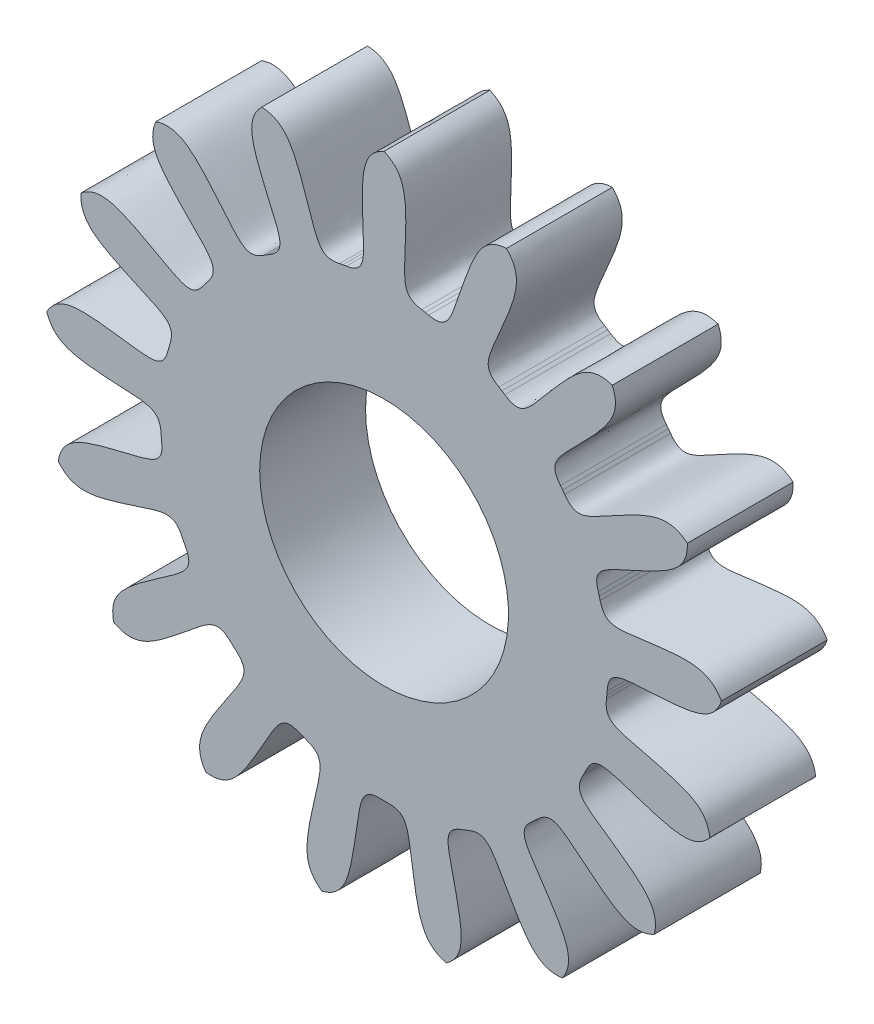
from build123d import *

# Parameters (mm, degrees)
BOSS_EXTRUDE1_17_TEETH_DEPTH = 0.6
CUT_EXTRUDE1_REACH           = 2.6
SKETCH2_R                    = 0.705


with BuildPart() as part:
    # Sketch1 → Boss-Extrude1 (17 teeth) (new body)
    with BuildSketch(Plane.XY):
        with BuildLine():
            Line((0.213306555, 1.249929723), (0.232994389, 1.24640989))
            Line((0.232994389, 1.24640989), (0.252624257, 1.242579971))
            add(Edge.make_bspline(
                [(0.693583999, 1.79034668), (0.578557942, 1.784358492), (0.516328, 1.691711636), (0.377605509, 1.288453607), (0.358256996, 1.220124862), (0.252624257, 1.242579971)],
                knots=[0, 0, 0, 0, 0.427279663, 0.527279663, 1, 1, 1, 1], degree=3))
            add(Edge.make_bspline(
                [(0.693583999, 1.79034668), (0.774555064, 1.708428802), (0.758127763, 1.598037909), (0.588971743, 1.206569891), (0.55723769, 1.14303933), (0.650429135, 1.08846954)],
                knots=[0, 0, 0, 0, 0.427279663, 0.527279663, 1, 1, 1, 1], degree=3))
            Line((0.650429135, 1.08846954), (0.667515983, 1.078075328))
            Line((0.667515983, 1.078075328), (0.684436763, 1.067412909))
            add(Edge.make_bspline(
                [(1.293495636, 1.418897121), (1.184073849, 1.454865506), (1.092578252, 1.390954933), (0.817549779, 1.065040364), (0.774824638, 1.008315196), (0.684436763, 1.067412909)],
                knots=[0, 0, 0, 0, 0.427279663, 0.527279663, 1, 1, 1, 1], degree=3))
            add(Edge.make_bspline(
                [(1.293495636, 1.418897121), (1.339406755, 1.313260852), (1.284210962, 1.216258635), (0.985063112, 0.912331783), (0.932522103, 0.864554961), (0.999707656, 0.780005514)],
                knots=[0, 0, 0, 0, 0.427279663, 0.527279663, 1, 1, 1, 1], degree=3))
            Line((0.999707656, 0.780005514), (1.011885844, 0.764140719))
            Line((1.011885844, 0.764140719), (1.023812292, 0.748085818))
            add(Edge.make_bspline(
                [(1.718713519, 0.855817643), (1.629674021, 0.928884872), (1.521269756, 0.90234206), (1.14707942, 0.697787518), (1.086747919, 0.660326976), (1.023812292, 0.748085818)],
                knots=[0, 0, 0, 0, 0.427279663, 0.527279663, 1, 1, 1, 1], degree=3))
            add(Edge.make_bspline(
                [(1.718713519, 0.855817643), (1.723364141, 0.740729747), (1.636854355, 0.670216894), (1.24811625, 0.494878211), (1.181864239, 0.469307654), (1.213970118, 0.366197422)],
                knots=[0, 0, 0, 0, 0.427279663, 0.527279663, 1, 1, 1, 1], degree=3))
            Line((1.213970118, 0.366197422), (1.219594916, 0.347004671))
            Line((1.219594916, 0.347004671), (1.224916298, 0.327725592))
            add(Edge.make_bspline(
                [(1.911809618, 0.17715525), (1.855177686, 0.277453188), (1.74450535, 0.291862891), (1.32168963, 0.236294602), (1.251899871, 0.223157938), (1.224916298, 0.327725592)],
                knots=[0, 0, 0, 0, 0.427279663, 0.527279663, 1, 1, 1, 1], degree=3))
            add(Edge.make_bspline(
                [(1.911809618, 0.17715525), (1.87457165, 0.068158985), (1.768431497, 0.033658647), (1.342604371, 0.010588595), (1.271589061, 0.010677747), (1.264279189, -0.097067662)],
                knots=[0, 0, 0, 0, 0.427279663, 0.527279663, 1, 1, 1, 1], degree=3))
            Line((1.264279189, -0.097067662), (1.262590936, -0.11699628))
            Line((1.262590936, -0.11699628), (1.26058857, -0.136895791))
            add(Edge.make_bspline(
                [(1.846705235, -0.525432941), (1.830129325, -0.411450085), (1.73213583, -0.358033979), (1.317798331, -0.25711121), (1.24797581, -0.244149815), (1.26058857, -0.136895791)],
                knots=[0, 0, 0, 0, 0.427279663, 0.527279663, 1, 1, 1, 1], degree=3))
            add(Edge.make_bspline(
                [(1.846705235, -0.525432941), (1.772607871, -0.613617026), (1.661172166, -0.607445387), (1.255766333, -0.475131069), (1.189578734, -0.449394248), (1.14384035, -0.54722322)],
                knots=[0, 0, 0, 0, 0.427279663, 0.527279663, 1, 1, 1, 1], degree=3))
            Line((1.14384035, -0.54722322), (1.135067053, -0.565196235))
            Line((1.135067053, -0.565196235), (1.126011371, -0.583028638))
            add(Edge.make_bspline(
                [(1.532193076, -1.157058502), (1.557911858, -1.044784745), (1.485831768, -0.959576376), (1.135931066, -0.715792728), (1.075505699, -0.678483783), (1.126011371, -0.583028638)],
                knots=[0, 0, 0, 0, 0.427279663, 0.527279663, 1, 1, 1, 1], degree=3))
            add(Edge.make_bspline(
                [(1.532193076, -1.157058502), (1.431243577, -1.212520657), (1.329562329, -1.166510555), (0.999330093, -0.89668165), (0.946909207, -0.84877306), (0.868919534, -0.92347325)],
                knots=[0, 0, 0, 0, 0.427279663, 0.527279663, 1, 1, 1, 1], degree=3))
            Line((0.868919534, -0.92347325), (0.854246076, -0.937063307))
            Line((0.854246076, -0.937063307), (0.839360096, -0.950420238))
            add(Edge.make_bspline(
                [(1.010749753, -1.632416901), (1.075289761, -1.537015436), (1.038857892, -1.431522666), (0.800650016, -1.077802472), (0.757782585, -1.021184757), (0.839360096, -0.950420238)],
                knots=[0, 0, 0, 0, 0.427279663, 0.527279663, 1, 1, 1, 1], degree=3))
            add(Edge.make_bspline(
                [(1.010749753, -1.632416901), (0.896581906, -1.647666655), (0.818387732, -1.568032009), (0.607928787, -1.197130405), (0.576354345, -1.133520367), (0.476646319, -1.175003101)],
                knots=[0, 0, 0, 0, 0.427279663, 0.527279663, 1, 1, 1, 1], degree=3))
            Line((0.476646319, -1.175003101), (0.458054433, -1.182374787))
            Line((0.458054433, -1.182374787), (0.43934859, -1.189452318))
            add(Edge.make_bspline(
                [(0.352799074, -1.887308351), (0.447443824, -1.821663675), (0.451580502, -1.710133888), (0.357236744, -1.29424902), (0.337716733, -1.22596907), (0.43934859, -1.189452318)],
                knots=[0, 0, 0, 0, 0.427279663, 0.527279663, 1, 1, 1, 1], degree=3))
            add(Edge.make_bspline(
                [(0.352799074, -1.887308351), (0.240831881, -1.860286141), (0.196685338, -1.757782052), (0.134423329, -1.335900066), (0.127959634, -1.265179468), (0.019999378, -1.267842271)],
                knots=[0, 0, 0, 0, 0.427279663, 0.527279663, 1, 1, 1, 1], degree=3))
            Line((0.019999378, -1.267842271), (0, -1.268))
            Line((0, -1.268), (-0.019999378, -1.267842271))
            add(Edge.make_bspline(
                [(-0.352799074, -1.887308351), (-0.240831881, -1.860286141), (-0.196685338, -1.757782052), (-0.134423329, -1.335900066), (-0.127959634, -1.265179468), (-0.019999378, -1.267842271)],
                knots=[0, 0, 0, 0, 0.427279663, 0.527279663, 1, 1, 1, 1], degree=3))
            add(Edge.make_bspline(
                [(-0.352799074, -1.887308351), (-0.447443824, -1.821663675), (-0.451580502, -1.710133888), (-0.357236744, -1.29424902), (-0.337716733, -1.22596907), (-0.43934859, -1.189452318)],
                knots=[0, 0, 0, 0, 0.427279663, 0.527279663, 1, 1, 1, 1], degree=3))
            Line((-0.43934859, -1.189452318), (-0.458054433, -1.182374787))
            Line((-0.458054433, -1.182374787), (-0.476646319, -1.175003101))
            add(Edge.make_bspline(
                [(-1.010749753, -1.632416901), (-0.896581906, -1.647666655), (-0.818387732, -1.568032009), (-0.607928787, -1.197130405), (-0.576354345, -1.133520367), (-0.476646319, -1.175003101)],
                knots=[0, 0, 0, 0, 0.427279663, 0.527279663, 1, 1, 1, 1], degree=3))
            add(Edge.make_bspline(
                [(-1.010749753, -1.632416901), (-1.075289761, -1.537015436), (-1.038857892, -1.431522666), (-0.800650016, -1.077802472), (-0.757782585, -1.021184757), (-0.839360096, -0.950420238)],
                knots=[0, 0, 0, 0, 0.427279663, 0.527279663, 1, 1, 1, 1], degree=3))
            Line((-0.839360096, -0.950420238), (-0.854246076, -0.937063307))
            Line((-0.854246076, -0.937063307), (-0.868919534, -0.92347325))
            add(Edge.make_bspline(
                [(-1.532193076, -1.157058502), (-1.431243577, -1.212520657), (-1.329562329, -1.166510555), (-0.999330093, -0.89668165), (-0.946909207, -0.84877306), (-0.868919534, -0.92347325)],
                knots=[0, 0, 0, 0, 0.427279663, 0.527279663, 1, 1, 1, 1], degree=3))
            add(Edge.make_bspline(
                [(-1.532193076, -1.157058502), (-1.557911858, -1.044784745), (-1.485831768, -0.959576376), (-1.135931066, -0.715792728), (-1.075505699, -0.678483783), (-1.126011371, -0.583028638)],
                knots=[0, 0, 0, 0, 0.427279663, 0.527279663, 1, 1, 1, 1], degree=3))
            Line((-1.126011371, -0.583028638), (-1.135067053, -0.565196235))
            Line((-1.135067053, -0.565196235), (-1.14384035, -0.54722322))
            add(Edge.make_bspline(
                [(-1.846705235, -0.525432941), (-1.772607871, -0.613617026), (-1.661172166, -0.607445387), (-1.255766333, -0.475131069), (-1.189578734, -0.449394248), (-1.14384035, -0.54722322)],
                knots=[0, 0, 0, 0, 0.427279663, 0.527279663, 1, 1, 1, 1], degree=3))
            add(Edge.make_bspline(
                [(-1.846705235, -0.525432941), (-1.830129325, -0.411450085), (-1.73213583, -0.358033979), (-1.317798331, -0.25711121), (-1.24797581, -0.244149815), (-1.26058857, -0.136895791)],
                knots=[0, 0, 0, 0, 0.427279663, 0.527279663, 1, 1, 1, 1], degree=3))
            Line((-1.26058857, -0.136895791), (-1.262590936, -0.11699628))
            Line((-1.262590936, -0.11699628), (-1.264279189, -0.097067662))
            add(Edge.make_bspline(
                [(-1.911809618, 0.17715525), (-1.87457165, 0.068158985), (-1.768431497, 0.033658647), (-1.342604371, 0.010588595), (-1.271589061, 0.010677747), (-1.264279189, -0.097067662)],
                knots=[0, 0, 0, 0, 0.427279663, 0.527279663, 1, 1, 1, 1], degree=3))
            add(Edge.make_bspline(
                [(-1.911809618, 0.17715525), (-1.855177686, 0.277453188), (-1.74450535, 0.291862891), (-1.32168963, 0.236294602), (-1.251899871, 0.223157938), (-1.224916298, 0.327725592)],
                knots=[0, 0, 0, 0, 0.427279663, 0.527279663, 1, 1, 1, 1], degree=3))
            Line((-1.224916298, 0.327725592), (-1.219594916, 0.347004671))
            Line((-1.219594916, 0.347004671), (-1.213970118, 0.366197422))
            add(Edge.make_bspline(
                [(-1.718713519, 0.855817643), (-1.723364141, 0.740729747), (-1.636854355, 0.670216894), (-1.24811625, 0.494878211), (-1.181864239, 0.469307654), (-1.213970118, 0.366197422)],
                knots=[0, 0, 0, 0, 0.427279663, 0.527279663, 1, 1, 1, 1], degree=3))
            add(Edge.make_bspline(
                [(-1.718713519, 0.855817643), (-1.629674021, 0.928884872), (-1.521269756, 0.90234206), (-1.14707942, 0.697787518), (-1.086747919, 0.660326976), (-1.023812292, 0.748085818)],
                knots=[0, 0, 0, 0, 0.427279663, 0.527279663, 1, 1, 1, 1], degree=3))
            Line((-1.023812292, 0.748085818), (-1.011885844, 0.764140719))
            Line((-1.011885844, 0.764140719), (-0.999707656, 0.780005514))
            add(Edge.make_bspline(
                [(-1.293495636, 1.418897121), (-1.339406755, 1.313260852), (-1.284210962, 1.216258635), (-0.985063112, 0.912331783), (-0.932522103, 0.864554961), (-0.999707656, 0.780005514)],
                knots=[0, 0, 0, 0, 0.427279663, 0.527279663, 1, 1, 1, 1], degree=3))
            add(Edge.make_bspline(
                [(-1.293495636, 1.418897121), (-1.184073849, 1.454865506), (-1.092578252, 1.390954933), (-0.817549779, 1.065040364), (-0.774824638, 1.008315196), (-0.684436763, 1.067412909)],
                knots=[0, 0, 0, 0, 0.427279663, 0.527279663, 1, 1, 1, 1], degree=3))
            Line((-0.684436763, 1.067412909), (-0.667515983, 1.078075328))
            Line((-0.667515983, 1.078075328), (-0.650429135, 1.08846954))
            add(Edge.make_bspline(
                [(-0.693583999, 1.79034668), (-0.774555064, 1.708428802), (-0.758127763, 1.598037909), (-0.588971743, 1.206569891), (-0.55723769, 1.14303933), (-0.650429135, 1.08846954)],
                knots=[0, 0, 0, 0, 0.427279663, 0.527279663, 1, 1, 1, 1], degree=3))
            add(Edge.make_bspline(
                [(-0.693583999, 1.79034668), (-0.578557942, 1.784358492), (-0.516328, 1.691711636), (-0.377605509, 1.288453607), (-0.358256996, 1.220124862), (-0.252624257, 1.242579971)],
                knots=[0, 0, 0, 0, 0.427279663, 0.527279663, 1, 1, 1, 1], degree=3))
            Line((-0.252624257, 1.242579971), (-0.232994389, 1.24640989))
            Line((-0.232994389, 1.24640989), (-0.213306555, 1.249929723))
            add(Edge.make_bspline(
                [(0, 1.92), (-0.10509542, 1.872863976), (-0.129655208, 1.763993308), (-0.113336477, 1.33785405), (-0.106695239, 1.267149904), (-0.213306555, 1.249929723)],
                knots=[0, 0, 0, 0, 0.427279663, 0.527279663, 1, 1, 1, 1], degree=3))
            add(Edge.make_bspline(
                [(0, 1.92), (0.10509542, 1.872863976), (0.129655208, 1.763993308), (0.113336477, 1.33785405), (0.106695239, 1.267149904), (0.213306555, 1.249929723)],
                knots=[0, 0, 0, 0, 0.427279663, 0.527279663, 1, 1, 1, 1], degree=3))
        make_face()
    extrude(amount=BOSS_EXTRUDE1_17_TEETH_DEPTH)

    # Sketch2 → Cut-Extrude1 (cut, up to next)
    with BuildSketch(Plane.XY, mode=Mode.PRIVATE) as cut_extrude1_sk1:
        Circle(SKETCH2_R)
    cut_extrude1_tool1 = extrude(cut_extrude1_sk1.sketch, amount=CUT_EXTRUDE1_REACH, mode=Mode.PRIVATE) & part.part
    add(cut_extrude1_tool1.solids().sort_by_distance((0, 0, 0))[0], mode=Mode.SUBTRACT)


solid = part.part
